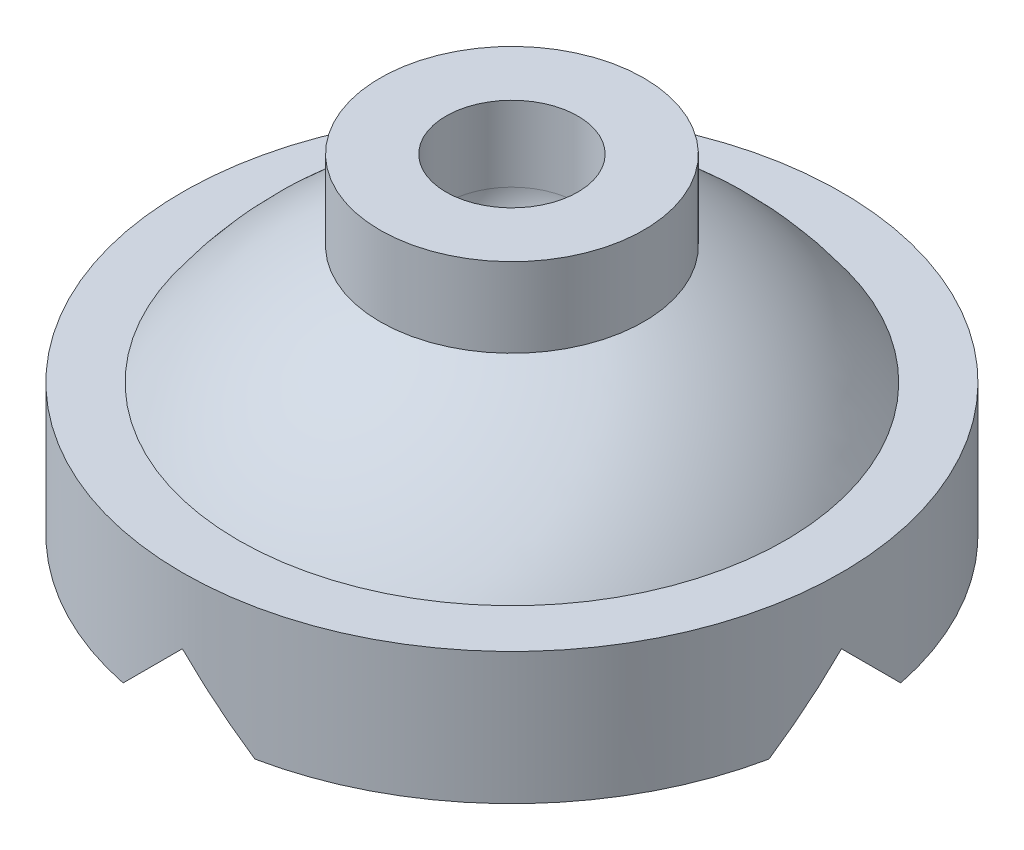
from build123d import *

# Parameters (mm, degrees)
CUT_EXTRUDE_1_DEPTH      = 30
CUT_EXTRUDE_2_DEPTH      = 26
CUT_EXTRUDE_2_DEPTH_BACK = 26


with BuildPart() as part:
    # Эскиз1 → Повернуть1 (revolve)
    with BuildSketch(Plane(origin=(0, 0, 0), x_dir=(0, 0, -1), z_dir=(1, 0, 0))):
        with BuildLine():
            Line((0, 0), (25, 0))
            Line((25, 0), (25, 10))
            Line((25, 10), (20.748340092, 10))
            ThreePointArc((20.748340092, 10), (15.979117923, 15.214609174), (10, 18.981275842))
            Line((10, 18.981275842), (10, 25))
            Line((10, 25), (5, 25))
            Line((5, 25), (5, 19.290902348))
            ThreePointArc((5, 19.290902348), (3.557868993, 15.701446772), (0, 14.183059008))
            Line((0, 14.183059008), (0, 0))
        make_face()
    revolve(axis=Axis((0, 30.068085096, 0), (0, -1, 0)))

    # Эскиз2 → Вырез-Вытянуть1 (cut, symmetric)
    with BuildSketch(Plane.XY):
        Polygon((-5, 0), (5, 0), (0, 5), align=None)
    extrude(amount=CUT_EXTRUDE_1_DEPTH, both=True, mode=Mode.SUBTRACT)

    # Эскиз3 → Вырез-Вытянуть2 (cut, two sides)
    with BuildSketch(Plane(origin=(0, 0, 0), x_dir=(0, 0, -1), z_dir=(1, 0, 0))) as cut_extrude_2_sk:
        Polygon((-5, 0), (0, 5), (5, 0), align=None)
    extrude(amount=CUT_EXTRUDE_2_DEPTH, mode=Mode.SUBTRACT)
    extrude(cut_extrude_2_sk.sketch, amount=-CUT_EXTRUDE_2_DEPTH_BACK, mode=Mode.SUBTRACT)


solid = part.part
